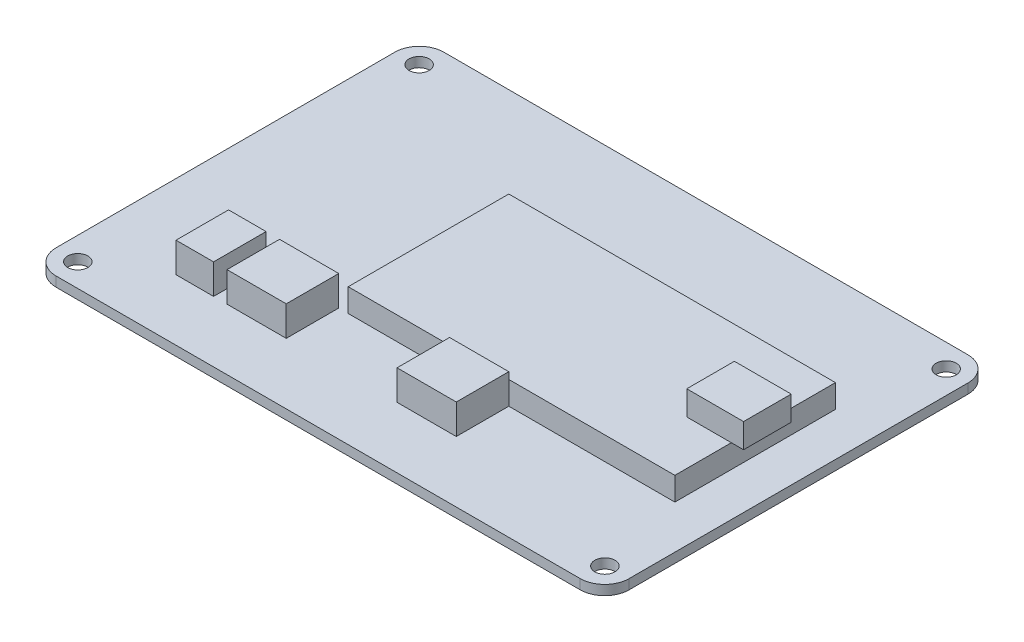
from build123d import *

# Parameters (mm, degrees)
SKETCH1_W           = 93.85
SKETCH1_H           = 63.5
SKETCH1_R           = 1.65
BOSS_EXTRUDE1_DEPTH = 1.6
FILLET1_R           = 4
SKETCH2_W           = 53.5
SKETCH2_H           = 26.3
BOSS_EXTRUDE2_DEPTH = 3.8
SKETCH3_W           = 9.3
SKETCH3_H           = 7.8
BOSS_EXTRUDE3_DEPTH = 4
SKETCH4_W           = 9.7
SKETCH4_H           = 8.6
SKETCH4_W_2         = 6.151959396
BOSS_EXTRUDE4_DEPTH = 4.9


with BuildPart() as part:
    # Sketch1 → Boss-Extrude1 (new body)
    with BuildSketch(Plane(origin=(0, 0, 0), x_dir=(1, 0, 0), z_dir=(0, 1, 0))):
        Rectangle(SKETCH1_W, SKETCH1_H)
        with Locations((-43.1625, 27.95)):
            Circle(SKETCH1_R, mode=Mode.SUBTRACT)
        with Locations((43.1625, 27.95)):
            Circle(SKETCH1_R, mode=Mode.SUBTRACT)
        with Locations((43.1625, -27.95)):
            Circle(SKETCH1_R, mode=Mode.SUBTRACT)
        with Locations((-43.1625, -27.95)):
            Circle(SKETCH1_R, mode=Mode.SUBTRACT)
    extrude(amount=BOSS_EXTRUDE1_DEPTH)

    # Fillet1
    fillet1_edges = [part.edges().sort_by_distance(p)[0] for p in [
        (46.925, 0.8, 31.75),
        (-46.925, 0.8, 31.75),
        (-46.925, 0.8, -31.75),
        (46.925, 0.8, -31.75),
    ]]
    fillet(fillet1_edges, radius=FILLET1_R)

    # Sketch2 → Boss-Extrude2 (add)
    with BuildSketch(Plane(origin=(0, 1.6, 0), x_dir=(1, 0, 0), z_dir=(0, 1, 0))):
        with Locations((13.075, 0)):
            Rectangle(SKETCH2_W, SKETCH2_H)
    extrude(amount=BOSS_EXTRUDE2_DEPTH)

    # Sketch3 → Boss-Extrude3 (add)
    with BuildSketch(Plane(origin=(0, 5.4, 0), x_dir=(1, 0, 0), z_dir=(0, 1, 0))):
        with Locations((37.175, 0)):
            Rectangle(SKETCH3_W, SKETCH3_H)
    extrude(amount=BOSS_EXTRUDE3_DEPTH)

    # Sketch4 → Boss-Extrude4 (add)
    with BuildSketch(Plane(origin=(0, 1.6, 0), x_dir=(1, 0, 0), z_dir=(0, 1, 0))):
        with Locations((7.775, -17.45)):
            Rectangle(SKETCH4_W, SKETCH4_H)
        with Locations((-20.075, -17.45)):
            Rectangle(SKETCH4_W, SKETCH4_H)
        with Locations((-30.200979698, -17.45)):
            Rectangle(SKETCH4_W_2, SKETCH4_H)
    extrude(amount=BOSS_EXTRUDE4_DEPTH)


solid = part.part
